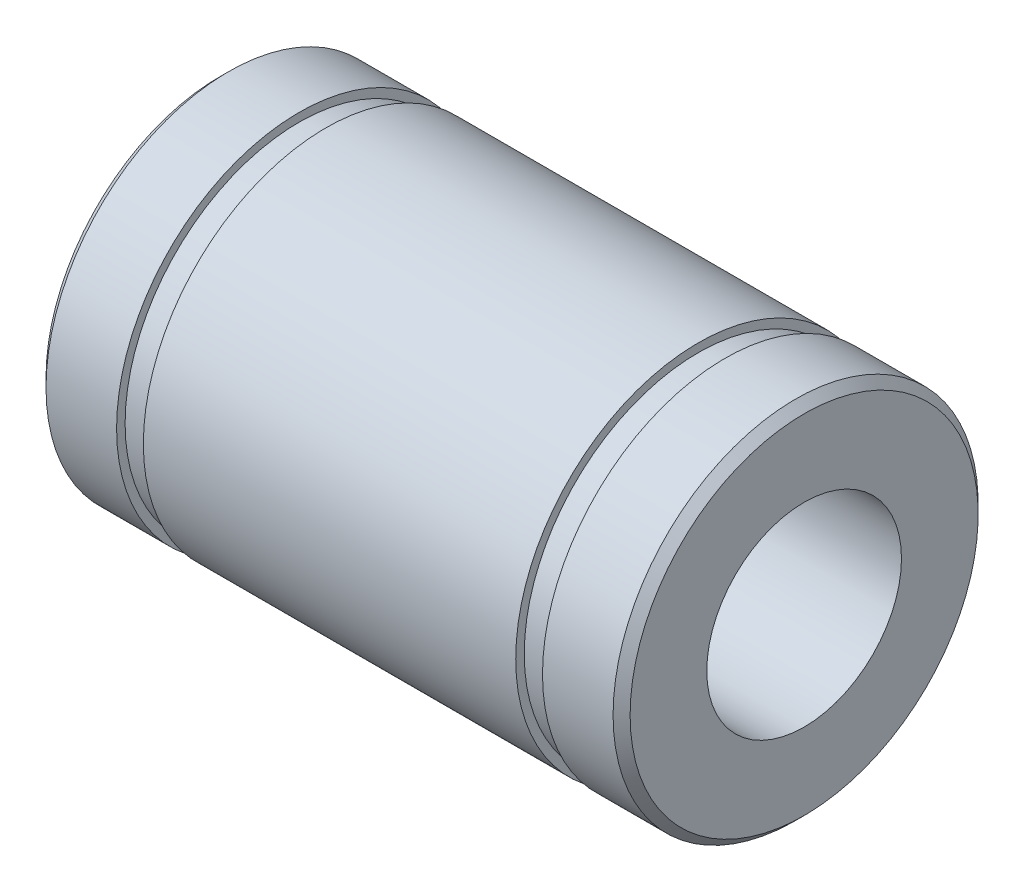
from build123d import *


with BuildPart() as part:
    # Эскиз1 → Повернуть1 (revolve)
    with BuildSketch(Plane(origin=(0, 0, 0), x_dir=(1, 0, 0), z_dir=(0, 1, 0))):
        Polygon((-11.65, -7.5), (-8.75, -7.5), (-8.75, -7.15), (-7.65, -7.15), (-7.65, -7.5), (7.65, -7.5), (7.65, -7.15), (8.75, -7.15), (8.75, -7.5), (11.65, -7.5), (12, -7.15), (12, -4), (-12, -4), (-12, -7.15), align=None)
    revolve(axis=Axis((-14.548038267, 0, 0), (1, 0, 0)))


solid = part.part
